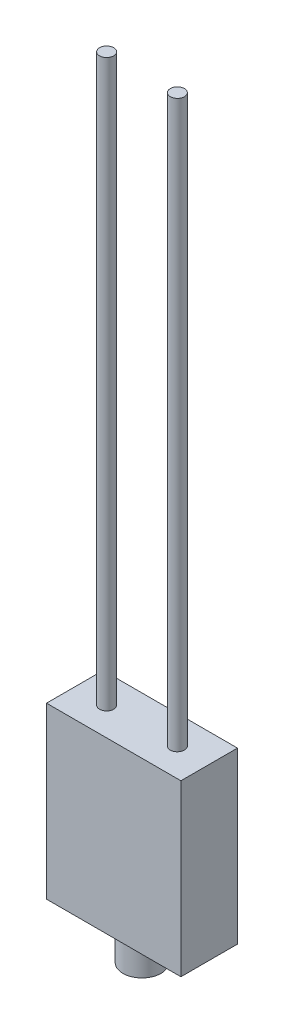
from build123d import *

# Parameters (mm, degrees)
SKETCH_1_W      = 19
SKETCH_1_H      = 8
EXTRUDE_1_DEPTH = 24
SKETCH_2_R      = 1
EXTRUDE_2_DEPTH = 80
SKETCH_3_R      = 2.686102283
EXTRUDE_3_DEPTH = 5


with BuildPart() as part:
    # 草图1 → 凸台-拉伸1 (new body)
    with BuildSketch(Plane(origin=(0, 0, 0), x_dir=(1, 0, 0), z_dir=(0, 1, 0))):
        Rectangle(SKETCH_1_W, SKETCH_1_H)
    extrude(amount=EXTRUDE_1_DEPTH)

    # 草图2 → 凸台-拉伸2 (add)
    with BuildSketch(Plane(origin=(0, 24, 0), x_dir=(1, 0, 0), z_dir=(0, 1, 0))):
        with Locations((5, 0)):
            Circle(SKETCH_2_R)
        with Locations((-5, 0)):
            Circle(SKETCH_2_R)
    extrude(amount=EXTRUDE_2_DEPTH)

    # 草图3 → 凸台-拉伸3 (add)
    with BuildSketch(Plane.XZ):
        Circle(SKETCH_3_R)
    extrude(amount=EXTRUDE_3_DEPTH)


solid = part.part
